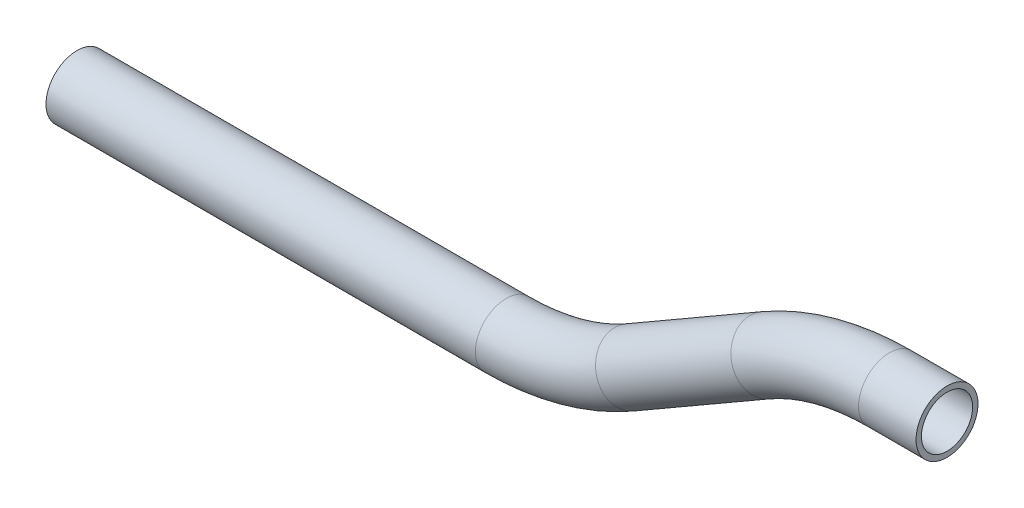
from build123d import *

# Parameters (mm, degrees)
SKETCH5_R   = 9.525
SKETCH5_R_2 = 7.874


with BuildPart() as part:
    # Sweep1: sweep along a path in Sketch4
    with BuildLine(Plane.XY) as sweep1_path:
        Line((45.216188471, 15.150806357), (27.533916935, 15.150806357))
        ThreePointArc((27.533916935, 15.150806357), (7.811905698, 12.55435432), (-10.566083065, 4.941942125))
        Line((-10.566083065, 4.941942125), (-52.191198388, -19.090329412))
        ThreePointArc((-52.191198388, -19.090329412), (-70.569187152, -26.702741607), (-90.291198388, -29.299193643))
        Line((-90.291198388, -29.299193643), (-222.273469925, -29.299193643))
    # Sketch5 → Sweep1 (sweep)
    with BuildSketch(Plane(origin=(45.216188471, 15.150806357, 0), x_dir=(0, 0, 1), z_dir=(-1, 0, 0))):
        Circle(SKETCH5_R)
        Circle(SKETCH5_R_2, mode=Mode.SUBTRACT)
    sweep(path=sweep1_path.line)


solid = part.part
